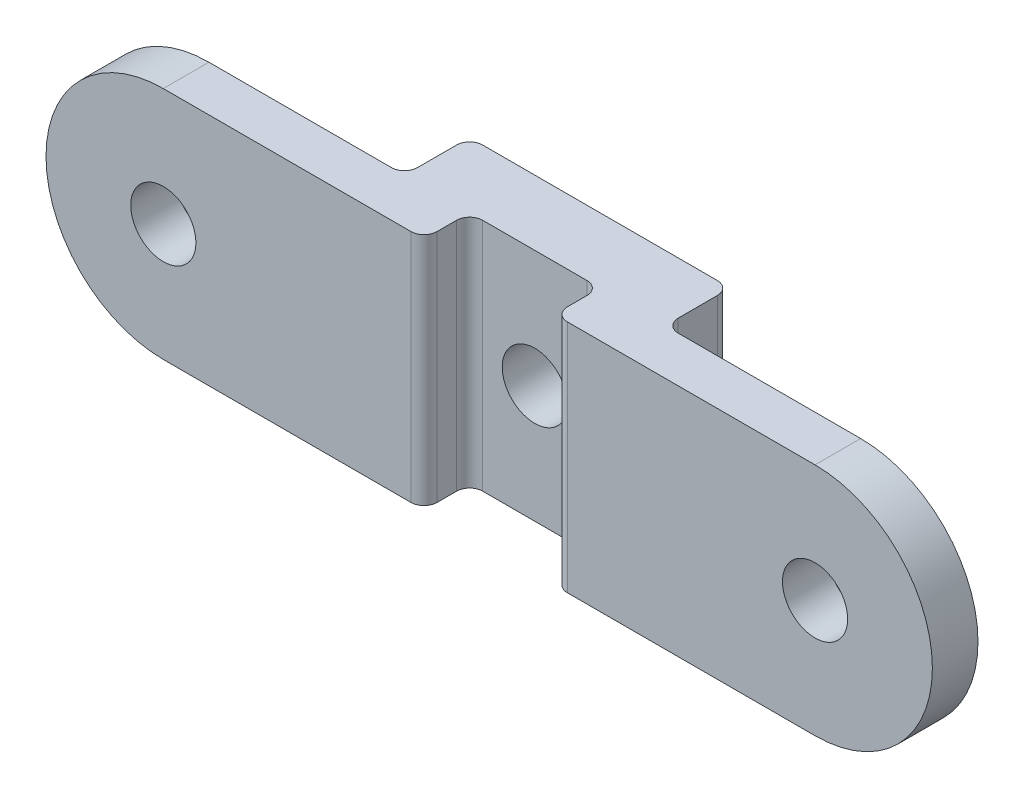
from build123d import *

# Parameters (mm, degrees)
SCHIZZO1_W                   = 20
SCHIZZO1_H                   = 18
SCHIZZO1_R                   = 2.5
ESTRUSIONE_ESTRUSIONE1_DEPTH = 5
SCHIZZO2_W                   = 30
SCHIZZO2_H                   = 3.5
ESTRUSIONE_ESTRUSIONE2_DEPTH = 18
RACCORDO2_R                  = 1
SCHIZZO3_R                   = 2.5
TAGLIO_ESTRUSIONE1_DEPTH     = 10


with BuildPart() as part:
    # Schizzo1 → Estrusione-Estrusione1 (new body)
    with BuildSketch(Plane.XY):
        Rectangle(SCHIZZO1_W, SCHIZZO1_H)
        Circle(SCHIZZO1_R, mode=Mode.SUBTRACT)
    extrude(amount=ESTRUSIONE_ESTRUSIONE1_DEPTH)

    # Schizzo2 → Estrusione-Estrusione2 (add, through all)
    with BuildSketch(Plane.XZ.offset(9)):
        with Locations((20, 6.75)):
            Rectangle(SCHIZZO2_W, SCHIZZO2_H)
        with Locations((-20, 6.75)):
            Rectangle(SCHIZZO2_W, SCHIZZO2_H)
    extrude(amount=-ESTRUSIONE_ESTRUSIONE2_DEPTH)

    # Raccordo2
    raccordo2_edges = [part.edges().sort_by_distance(p)[0] for p in [
        (-10, 0, 5),
        (-5, 0, 5),
        (-5, 0, 8.5),
        (5, 0, 5),
        (5, 0, 8.5),
        (10, 0, 5),
        (-10, 0, 0),
        (10, 0, 0),
    ]]
    fillet(raccordo2_edges, radius=RACCORDO2_R)

    # Schizzo3 → Taglio-Estrusione1 (cut)
    with BuildSketch(Plane.XY.offset(8.5)):
        with Locations((-25, 0)):
            Circle(SCHIZZO3_R)
        with Locations((25, 0)):
            Circle(SCHIZZO3_R)
        with BuildLine():
            Line((25, 9), (35, 9))
            Line((35, 9), (35, -9))
            Line((35, -9), (25, -9))
            ThreePointArc((25, -9), (34, 0), (25, 9))
        make_face()
        with BuildLine():
            Line((-35, 9), (-35, -9))
            Line((-35, -9), (-25, -9))
            ThreePointArc((-25, -9), (-34, 0), (-25, 9))
            Line((-25, 9), (-35, 9))
        make_face()
    extrude(amount=-TAGLIO_ESTRUSIONE1_DEPTH, mode=Mode.SUBTRACT)


solid = part.part
